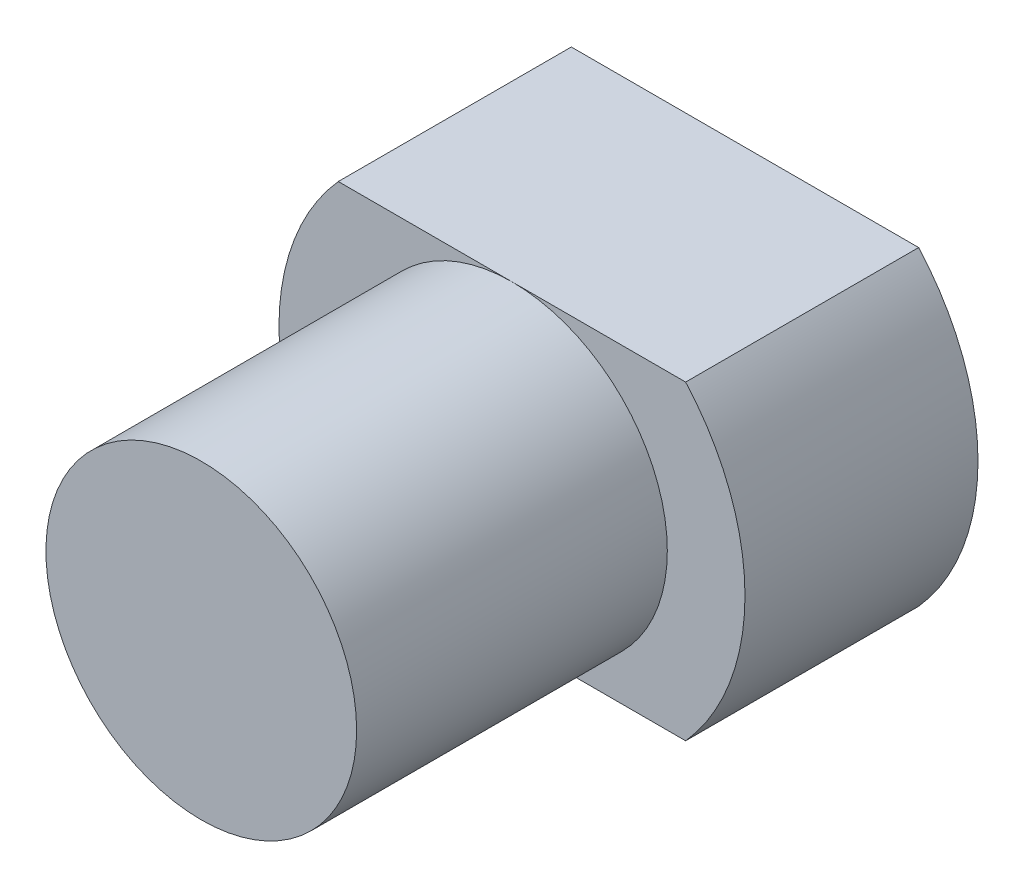
from build123d import *

# Parameters (mm, degrees)
BOSS_EXTRUDE1_DEPTH = 19.05
SKETCH3_R           = 12.7
BOSS_EXTRUDE2_DEPTH = 25.4


with BuildPart() as part:
    # Sketch2 → Boss-Extrude1 (new body)
    with BuildSketch(Plane.XY):
        with BuildLine():
            Line((-14.199031657, 12.7), (14.199031657, 12.7))
            ThreePointArc((14.199031657, 12.7), (19.05, 0), (14.199031657, -12.7))
            Line((14.199031657, -12.7), (-14.199031657, -12.7))
            ThreePointArc((-14.199031657, -12.7), (-19.05, 0), (-14.199031657, 12.7))
        make_face()
    extrude(amount=BOSS_EXTRUDE1_DEPTH)

    # Sketch3 → Boss-Extrude2 (add)
    with BuildSketch(Plane.XY.offset(19.05)):
        Circle(SKETCH3_R)
    extrude(amount=BOSS_EXTRUDE2_DEPTH)


solid = part.part
